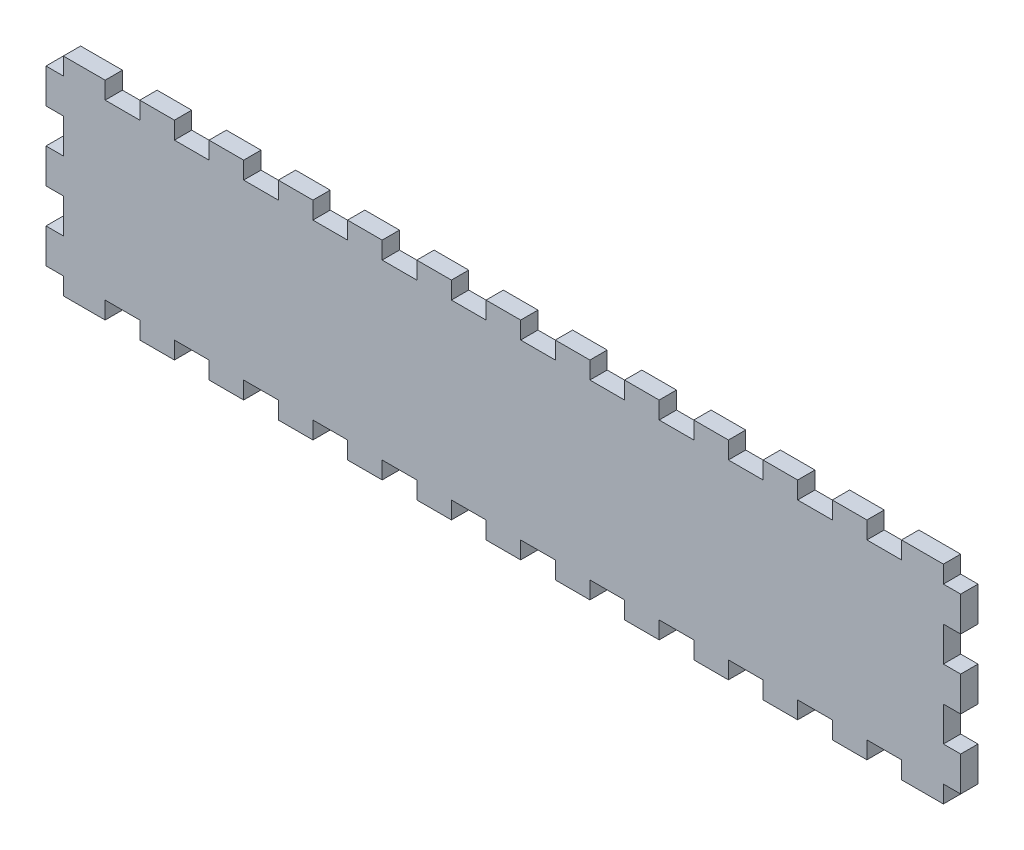
from build123d import *

# Parameters (mm, degrees)
BOSS_EXTRUDE1_DEPTH = 6
SKETCH3_W           = 12
SKETCH3_H           = 6
CUT_EXTRUDE1_DEPTH  = 6


with BuildPart() as part:
    # Sketch2 → Boss-Extrude1 (new body)
    with BuildSketch(Plane.XY.offset(-6)):
        Polygon((-152.5, 6), (-138, 6), (-138, 0), (-126, 0), (-126, 6), (-114, 6), (-114, 0), (-102, 0), (-102, 6), (-90, 6), (-90, 0), (-78, 0), (-78, 6), (-66, 6), (-66, 0), (-54, 0), (-54, 6), (-42, 6), (-42, 0), (-30, 0), (-30, 6), (-18, 6), (-18, 0), (-6, 0), (-6, 6), (6, 6), (6, 0), (18, 0), (18, 6), (30, 6), (30, 0), (42, 0), (42, 6), (54, 6), (54, 0), (66, 0), (66, 6), (78, 6), (78, 0), (90, 0), (90, 6), (102, 6), (102, 0), (114, 0), (114, 6), (126, 6), (126, 0), (138, 0), (138, 6), (152.5, 6), (152.5, 0), (158.5, 0), (158.5, -12), (152.5, -12), (152.5, -24), (158.5, -24), (158.5, -36), (152.5, -36), (152.5, -48), (158.5, -48), (158.5, -60), (152.5, -60), (152.5, -66), (-152.5, -66), (-152.5, -60), (-158.5, -60), (-158.5, -48), (-152.5, -48), (-152.5, -36), (-158.5, -36), (-158.5, -24), (-152.5, -24), (-152.5, -12), (-158.5, -12), (-158.5, 0), (-152.5, 0), align=None)
    extrude(amount=BOSS_EXTRUDE1_DEPTH)

    # Sketch3 → Cut-Extrude1 (cut)
    with BuildSketch(Plane.XY):
        with Locations((-132, -63)):
            Rectangle(SKETCH3_W, SKETCH3_H)
        with Locations((-108, -63)):
            Rectangle(SKETCH3_W, SKETCH3_H)
        with Locations((-84, -63)):
            Rectangle(SKETCH3_W, SKETCH3_H)
        with Locations((-60, -63)):
            Rectangle(SKETCH3_W, SKETCH3_H)
        with Locations((-36, -63)):
            Rectangle(SKETCH3_W, SKETCH3_H)
        with Locations((-12, -63)):
            Rectangle(SKETCH3_W, SKETCH3_H)
        with Locations((12, -63)):
            Rectangle(SKETCH3_W, SKETCH3_H)
        with Locations((36, -63)):
            Rectangle(SKETCH3_W, SKETCH3_H)
        with Locations((60, -63)):
            Rectangle(SKETCH3_W, SKETCH3_H)
        with Locations((84, -63)):
            Rectangle(SKETCH3_W, SKETCH3_H)
        with Locations((108, -63)):
            Rectangle(SKETCH3_W, SKETCH3_H)
        with Locations((132, -63)):
            Rectangle(SKETCH3_W, SKETCH3_H)
    extrude(amount=-CUT_EXTRUDE1_DEPTH, mode=Mode.SUBTRACT)


solid = part.part
